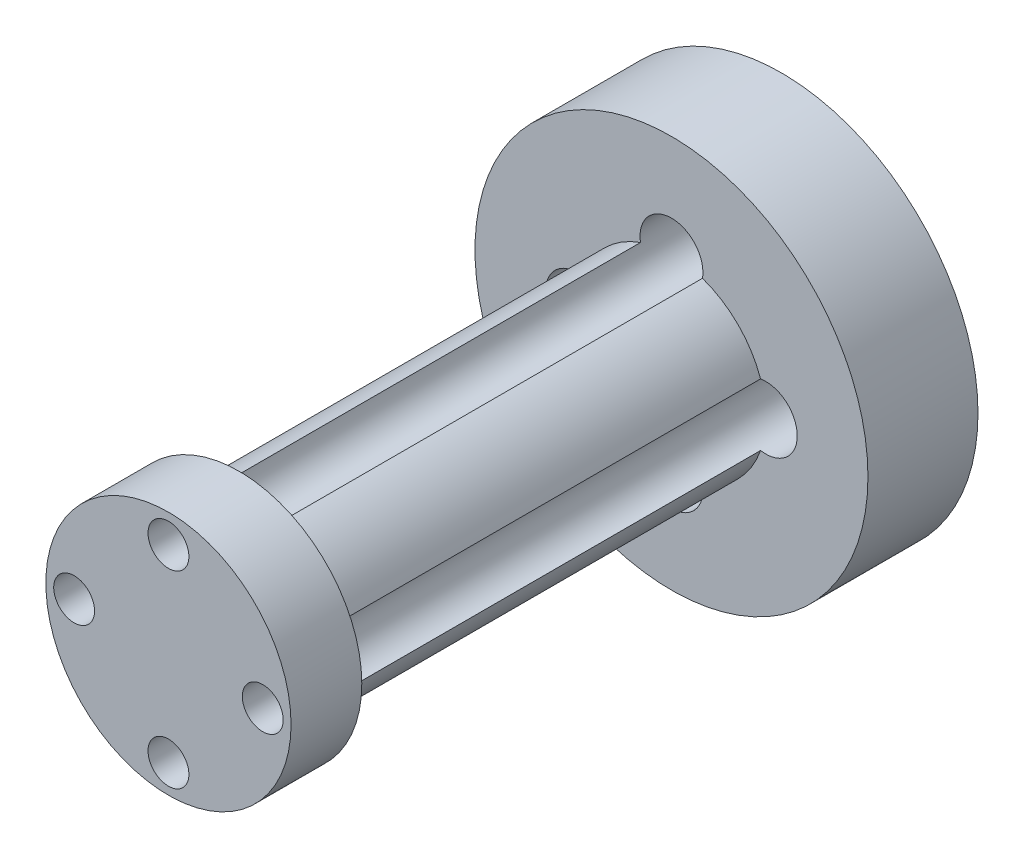
from build123d import *

# Parameters (mm, degrees)
SKETCH1_R           = 12.5
BOSS_EXTRUDE1_DEPTH = 7
SKETCH2_R           = 6
BOSS_EXTRUDE2_DEPTH = 27.5
SKETCH3_R           = 2
CUT_EXTRUDE1_DEPTH  = 35.5
SKETCH4_R           = 2.07
CUT_EXTRUDE2_DEPTH  = 5
SKETCH5_R           = 7.8
BOSS_EXTRUDE3_DEPTH = 4.5
SKETCH6_R           = 1.3
CUT_EXTRUDE3_DEPTH  = 4.5


with BuildPart() as part:
    # Sketch1 → Boss-Extrude1 (new body)
    with BuildSketch(Plane.XY):
        Circle(SKETCH1_R)
    extrude(amount=BOSS_EXTRUDE1_DEPTH)

    # Sketch2 → Boss-Extrude2 (add)
    with BuildSketch(Plane.XY.offset(7)):
        Circle(SKETCH2_R)
    extrude(amount=BOSS_EXTRUDE2_DEPTH)

    # Sketch3 → Cut-Extrude1 (cut, through all)
    with BuildSketch(Plane.XY.offset(34.5)):
        with Locations((0, 6)):
            Circle(SKETCH3_R)
        with Locations((6, 0)):
            Circle(SKETCH3_R)
        with Locations((0, -6)):
            Circle(SKETCH3_R)
        with Locations((-6, 0)):
            Circle(SKETCH3_R)
    extrude(amount=-CUT_EXTRUDE1_DEPTH, mode=Mode.SUBTRACT)

    # Sketch4 → Cut-Extrude2 (cut)
    with BuildSketch(Plane(origin=(0, 0, 0), x_dir=(-1, 0, 0), z_dir=(0, 0, -1))):
        with Locations((5.727564928, 5.727564928)):
            Circle(SKETCH4_R)
        with Locations((-5.727564928, -5.727564928)):
            Circle(SKETCH4_R)
    extrude(amount=-CUT_EXTRUDE2_DEPTH, mode=Mode.SUBTRACT)

    # Sketch5 → Boss-Extrude3 (add)
    with BuildSketch(Plane.XY.offset(34.5)):
        Circle(SKETCH5_R)
    extrude(amount=BOSS_EXTRUDE3_DEPTH)

    # Sketch6 → Cut-Extrude3 (cut)
    with BuildSketch(Plane.XY.offset(39)):
        with Locations((-6, 0)):
            Circle(SKETCH6_R)
        with Locations((0, 6)):
            Circle(SKETCH6_R)
        with Locations((6, 0)):
            Circle(SKETCH6_R)
        with Locations((0, -6)):
            Circle(SKETCH6_R)
    extrude(amount=-CUT_EXTRUDE3_DEPTH, mode=Mode.SUBTRACT)


solid = part.part
